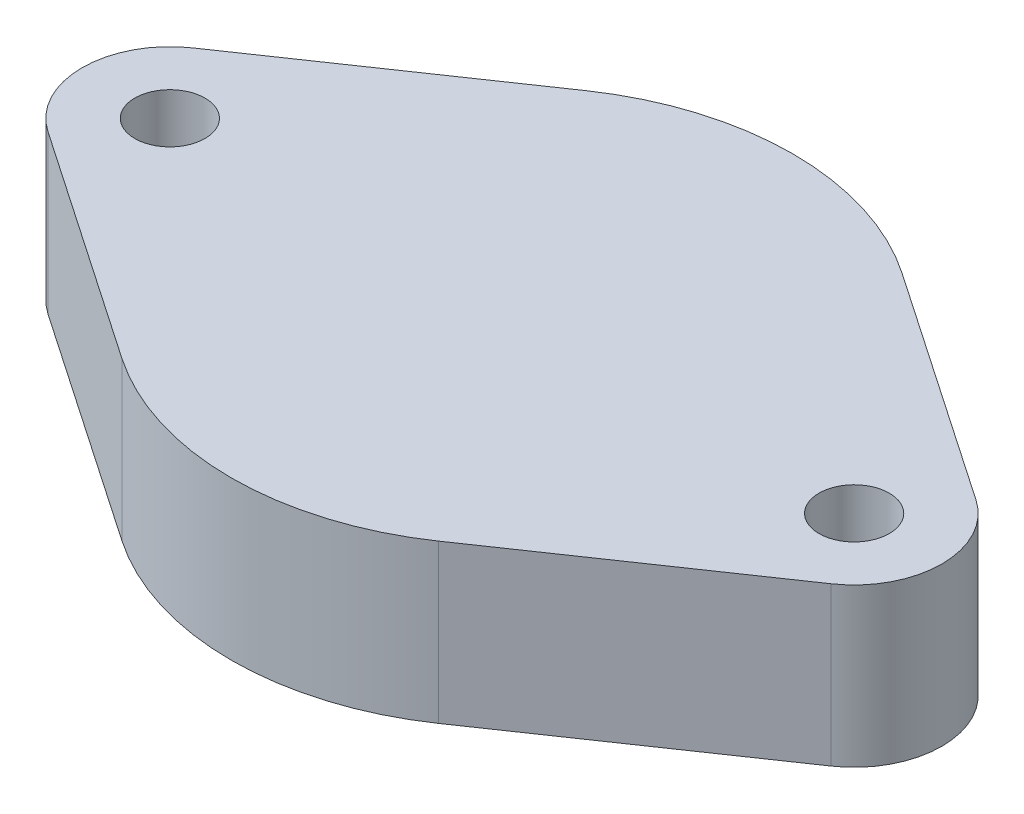
from build123d import *

# Parameters (mm, degrees)
SKETCH_1_R      = 2
EXTRUDE_1_DEPTH = 9


with BuildPart() as part:
    # 草圖1 → 填料-伸長1 (new body)
    with BuildSketch(Plane(origin=(0, 0, 0), x_dir=(1, 0, 0), z_dir=(0, 1, 0))):
        with BuildLine():
            Line((-22.320512821, 4.128523638), (-9.025641026, 13.211275642))
            ThreePointArc((-9.025641026, 13.211275642), (0, 16), (9.025641026, 13.211275642))
            Line((9.025641026, 13.211275642), (22.320512821, 4.128523638))
            ThreePointArc((22.320512821, 4.128523638), (24.5, 0), (22.320512821, -4.128523638))
            Line((22.320512821, -4.128523638), (9.025641026, -13.211275642))
            ThreePointArc((9.025641026, -13.211275642), (0, -16), (-9.025641026, -13.211275642))
            Line((-9.025641026, -13.211275642), (-22.320512821, -4.128523638))
            ThreePointArc((-22.320512821, -4.128523638), (-24.5, 0), (-22.320512821, 4.128523638))
        make_face()
        with Locations((19.5, 0)):
            Circle(SKETCH_1_R, mode=Mode.SUBTRACT)
        with Locations((-19.5, 0)):
            Circle(SKETCH_1_R, mode=Mode.SUBTRACT)
    extrude(amount=EXTRUDE_1_DEPTH)


solid = part.part
